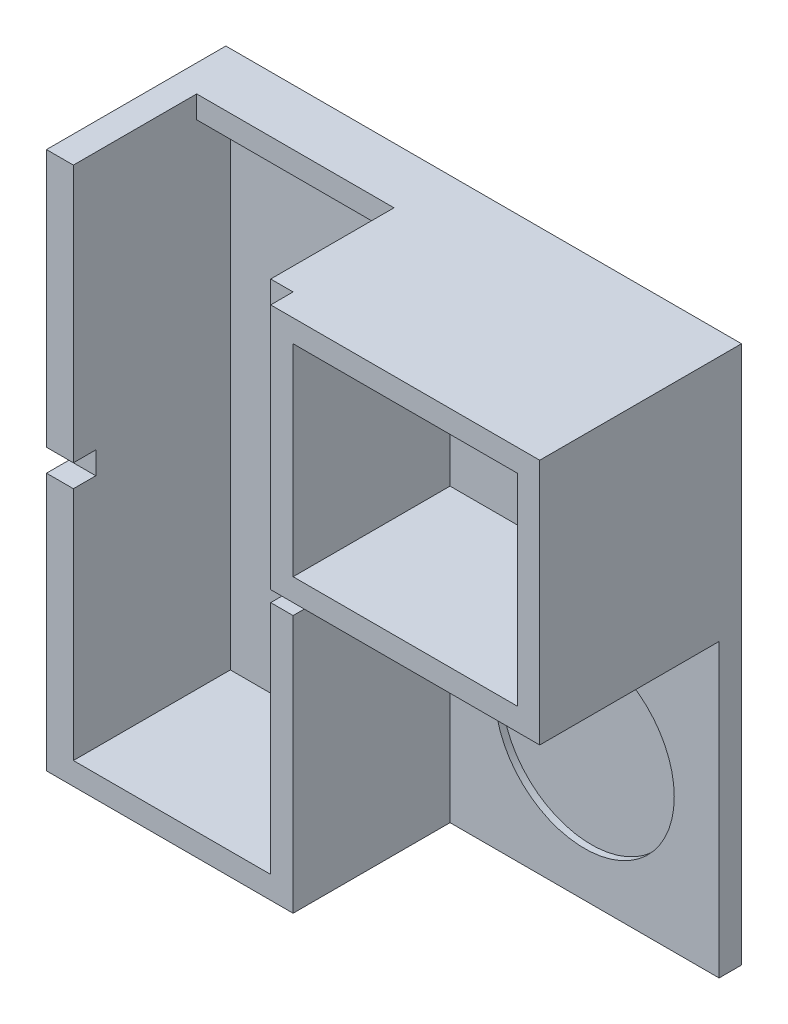
from build123d import *

# Parameters (mm, degrees)
RESSALTO_EXTRUS_O1_DEPTH = 10
ESBO_O2_W                = 10
ESBO_O2_H                = 10
ESBO_O2_W_2              = 210
ESBO_O2_H_2              = 220
RESSALTO_EXTRUS_O4_DEPTH = 70
ESBO_O7_R                = 40
CORTE_EXTRUS_O1_DEPTH    = 3
ESBO_O21_W               = 200
ESBO_O21_H               = 45
CORTE_EXTRUS_O5_DEPTH    = 100
RESSALTO_EXTRUS_O5_DEPTH = 80
ESBO_O29_W               = 110
ESBO_O29_H               = 80
CORTE_EXTRUS_O8_DEPTH    = 250
ESBO_O30_W               = 12
ESBO_O30_H               = 10
RESSALTO_EXTRUS_O6_DEPTH = 50
ESBO_O31_W               = 100
ESBO_O31_H               = 90
CORTE_EXTRUS_O9_DEPTH    = 70
ESBO_O38_W               = 12
ESBO_O38_H               = 70
RESSALTO_EXTRUS_O8_DEPTH = 220
ESBO_O39_W               = 10
ESBO_O39_H               = 10
ESBO_O39_W_2             = 12
CORTE_EXTRUS_O10_DEPTH   = 10
ESBO_O40_W               = 88
ESBO_O40_H               = 10
CORTE_EXTRUS_O11_DEPTH   = 10


with BuildPart() as part:
    # Esboço1 → Ressalto-extrusão1 (new body)
    with BuildSketch(Plane.XY):
        Polygon((-99.217703787, 25.02394247), (70.782296213, 25.02394247), (70.782296213, 0), (70.782296213, -214.97605753), (-99.217703787, -214.97605753), (-269.217703787, -214.97605753), (-269.217703787, 0), (-269.217703787, 25.02394247), align=None)
    extrude(amount=RESSALTO_EXTRUS_O1_DEPTH)

    # Esboço2 → Ressalto-extrusão4 (add)
    with BuildSketch(Plane.XY.offset(10)):
        with Locations((-54.217703787, -209.97605753)):
            Rectangle(ESBO_O2_W, ESBO_O2_H)
        with Locations((-164.217703787, -209.97605753)):
            Rectangle(ESBO_O2_W_2, ESBO_O2_H)
        with Locations((-54.217703787, -94.97605753)):
            Rectangle(ESBO_O2_W, ESBO_O2_H_2)
        Polygon((-59.217703787, 15.02394247), (-49.217703787, 15.02394247), (-49.217703787, 25.02394247), (-269.217703787, 25.02394247), (-269.217703787, 15.02394247), align=None)
    extrude(amount=RESSALTO_EXTRUS_O4_DEPTH)

    # Esboço7 → Corte-extrusão1 (cut)
    with BuildSketch(Plane.XY.offset(10)):
        with Locations((10.782296213, -154.97605753)):
            Circle(ESBO_O7_R)
    extrude(amount=-CORTE_EXTRUS_O1_DEPTH, mode=Mode.SUBTRACT)

    # Esboço21 → Corte-extrusão5 (cut)
    with BuildSketch(Plane(origin=(0, 25.02394247, 0), x_dir=(1, 0, 0), z_dir=(0, 1, 0))):
        with Locations((-159.217703787, -47.5)):
            Rectangle(ESBO_O21_W, ESBO_O21_H)
    extrude(amount=-CORTE_EXTRUS_O5_DEPTH, mode=Mode.SUBTRACT)

    # Esboço28 → Ressalto-extrusão5 (add)
    with BuildSketch(Plane.XY.offset(10)):
        Polygon((70.782296213, -84.97605753), (70.782296213, 25.02394247), (60.782296213, 25.02394247), (-39.217703787, 25.02394247), (-49.217703787, 25.02394247), (-49.217703787, -74.97605753), (-49.217703787, -84.97605753), align=None)
    extrude(amount=RESSALTO_EXTRUS_O5_DEPTH)

    # Esboço29 → Corte-extrusão8 (cut)
    with BuildSketch(Plane.XZ.offset(214.97605753)):
        with Locations((-214.217703787, 40)):
            Rectangle(ESBO_O29_W, ESBO_O29_H)
    extrude(amount=-CORTE_EXTRUS_O8_DEPTH, mode=Mode.SUBTRACT)

    # Esboço30 → Ressalto-extrusão6 (add)
    with BuildSketch(Plane.XY.offset(25)):
        with Locations((-153.217703787, 20.02394247)):
            Rectangle(ESBO_O30_W, ESBO_O30_H)
    extrude(amount=RESSALTO_EXTRUS_O6_DEPTH)

    # Esboço31 → Corte-extrusão9 (cut)
    with BuildSketch(Plane.XY.offset(90)):
        with Locations((10.782296213, -29.97605753)):
            Rectangle(ESBO_O31_W, ESBO_O31_H)
    extrude(amount=-CORTE_EXTRUS_O9_DEPTH, mode=Mode.SUBTRACT)

    # Esboço38 → Ressalto-extrusão8 (add)
    with BuildSketch(Plane.XZ.offset(-15.02394247)):
        with Locations((-153.217703787, 45)):
            Rectangle(ESBO_O38_W, ESBO_O38_H)
    extrude(amount=RESSALTO_EXTRUS_O8_DEPTH)

    # Esboço39 → Corte-extrusão10 (cut)
    with BuildSketch(Plane.XY.offset(80)):
        with Locations((-54.217703787, -94.97605753)):
            Rectangle(ESBO_O39_W, ESBO_O39_H)
        with Locations((-153.217703787, -94.97605753)):
            Rectangle(ESBO_O39_W_2, ESBO_O39_H)
    extrude(amount=-CORTE_EXTRUS_O10_DEPTH, mode=Mode.SUBTRACT)

    # Esboço40 → Corte-extrusão11 (cut)
    with BuildSketch(Plane(origin=(0, 25.02394247, 0), x_dir=(1, 0, 0), z_dir=(0, 1, 0))):
        with Locations((-103.217703787, -75)):
            Rectangle(ESBO_O40_W, ESBO_O40_H)
    extrude(amount=-CORTE_EXTRUS_O11_DEPTH, mode=Mode.SUBTRACT)


solid = part.part
